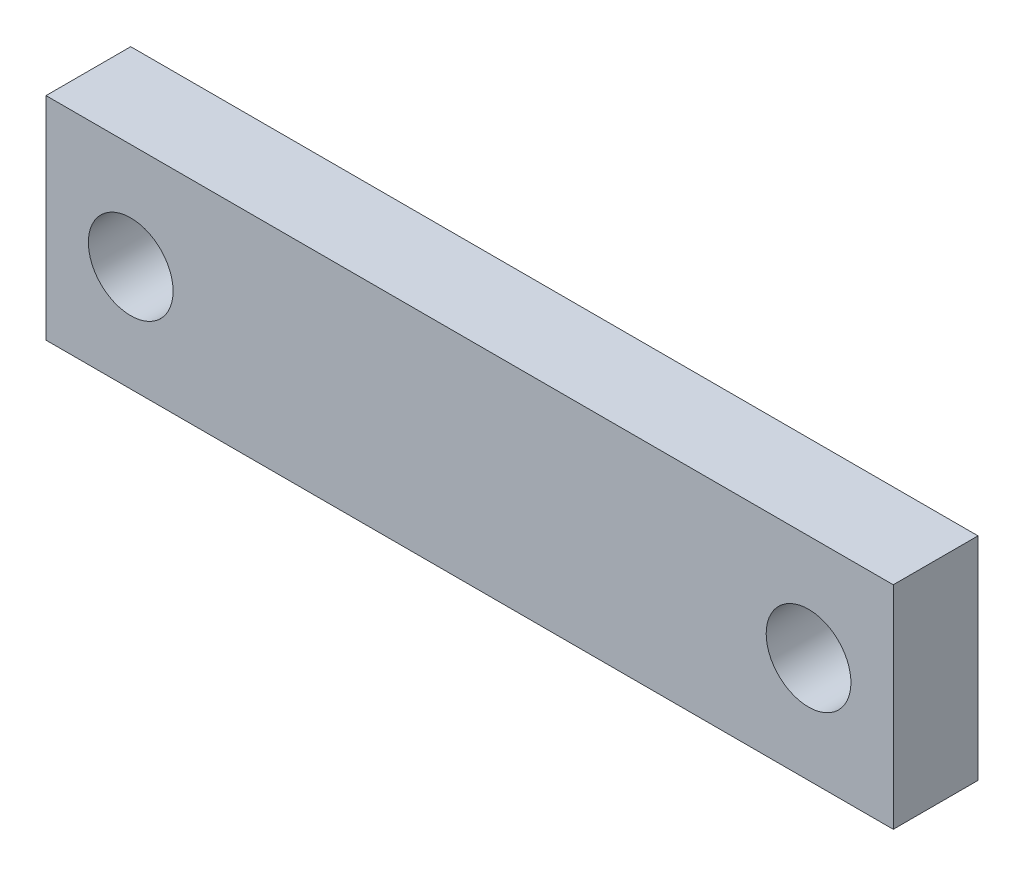
from build123d import *

# Parameters (mm, degrees)
SKETCH1_W           = 20
SKETCH1_H           = 5
SKETCH1_R           = 1
BOSS_EXTRUDE1_DEPTH = 2


with BuildPart() as part:
    # Sketch1 → Boss-Extrude1 (new body)
    with BuildSketch(Plane.XY):
        Rectangle(SKETCH1_W, SKETCH1_H)
        with Locations((-8, 0)):
            Circle(SKETCH1_R, mode=Mode.SUBTRACT)
        with Locations((8, 0)):
            Circle(SKETCH1_R, mode=Mode.SUBTRACT)
    extrude(amount=BOSS_EXTRUDE1_DEPTH)


solid = part.part
